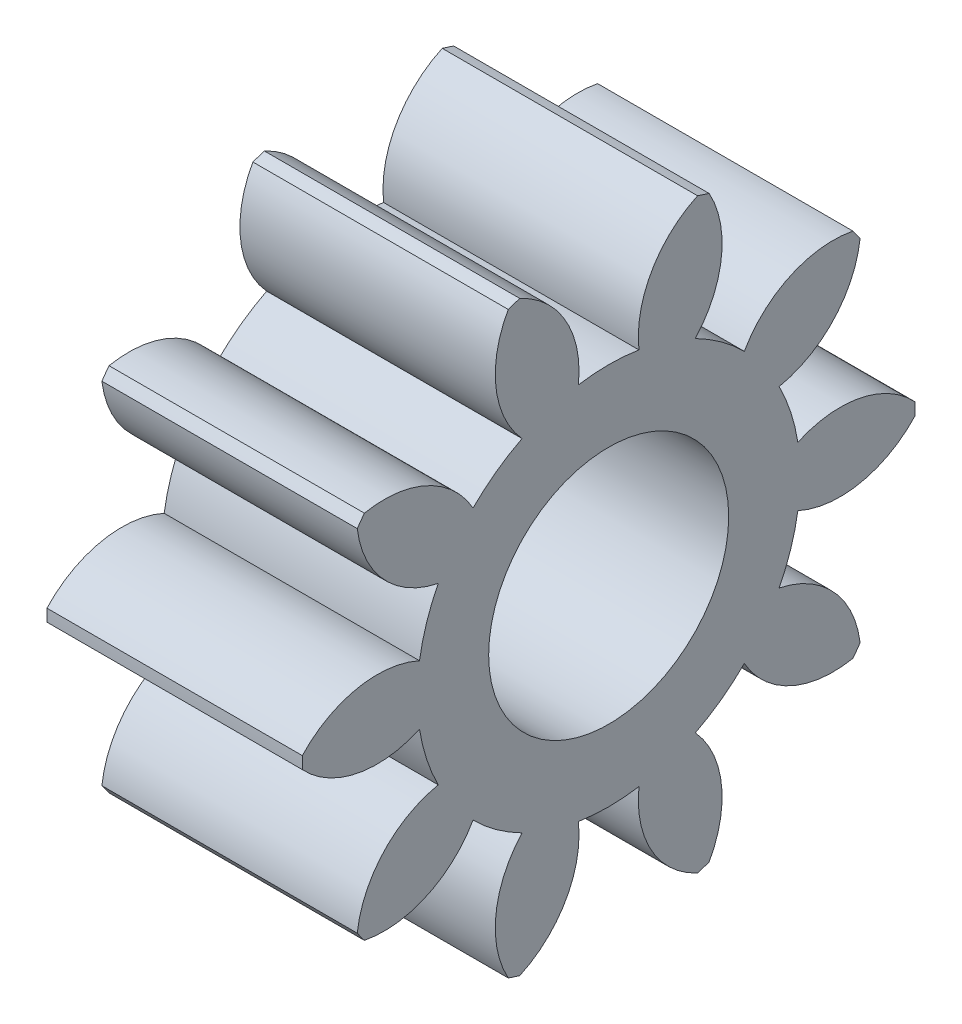
from build123d import *

# Parameters (mm, degrees)
BASPROSKE_W        = 5
BASPROSKE_H        = 6
TOOTHCUT_DEPTH     = 10.848857802
TEETHCUTS_COUNT    = 10
TEETHCUTS_ANGLE    = 324
BORSKE_R           = 0.4
BORE_DEPTH         = 50.0000508
SKETCH1_R          = 2.35
CUT_EXTRUDE1_DEPTH = 10.693816982


with BuildPart() as part:
    # BasProSke → Base-Revolve (revolve)
    with BuildSketch(Plane(origin=(0, 0, 0), x_dir=(1, 0, 0), z_dir=(0, 1, 0)), mode=Mode.PRIVATE) as base_revolve_sk:
        with Locations((2.5, 3)):
            Rectangle(BASPROSKE_W, BASPROSKE_H)
    revolve(base_revolve_sk.sketch.rotate(Axis((-10, 0, 0), (1, 0, 0)), 180), axis=Axis((-10, 0, 0), (1, 0, 0)))

    # TooCutSke → ToothCut (cut, through all)
    with BuildSketch(Plane(origin=(0, 0, 0), x_dir=(0, 0, -1), z_dir=(1, 0, 0))):
        with BuildLine():
            ThreePointArc((0.59278292, 3.701838653), (0, 3.749), (-0.59278292, 3.701838653))
            ThreePointArc((-0.59278292, 3.701838653), (-0.846593509, 4.924114224), (-1.775771316, 5.757784417))
            ThreePointArc((-1.775771316, 5.757784417), (0, 6.0254), (1.775771316, 5.757784417))
            ThreePointArc((1.775771316, 5.757784417), (0.846593509, 4.924114224), (0.59278292, 3.701838653))
        make_face()
    toothcut = extrude(amount=TOOTHCUT_DEPTH, mode=Mode.SUBTRACT)

    # TeethCuts: ToothCut ×10 about axis
    teethcuts_axis = Axis((-10, 0, 0), (1, 0, 0))
    for i in range(1, TEETHCUTS_COUNT):
        add(toothcut.rotate(teethcuts_axis, i * TEETHCUTS_ANGLE / (TEETHCUTS_COUNT - 1)), mode=Mode.SUBTRACT)

    # BorSke → Bore (cut, symmetric)
    with BuildSketch(Plane(origin=(0, 0, 0), x_dir=(0, 0, -1), z_dir=(1, 0, 0))):
        with Locations(Location((0, 0, 0), (0, 0, 180))):
            Circle(BORSKE_R)
    extrude(amount=BORE_DEPTH, both=True, mode=Mode.SUBTRACT)

    # Sketch1 → Cut-Extrude1 (cut, through all)
    with BuildSketch(Plane(origin=(5, 0, 0), x_dir=(0, 0, -1), z_dir=(1, 0, 0))):
        Circle(SKETCH1_R)
    extrude(amount=-CUT_EXTRUDE1_DEPTH, mode=Mode.SUBTRACT)


solid = part.part
